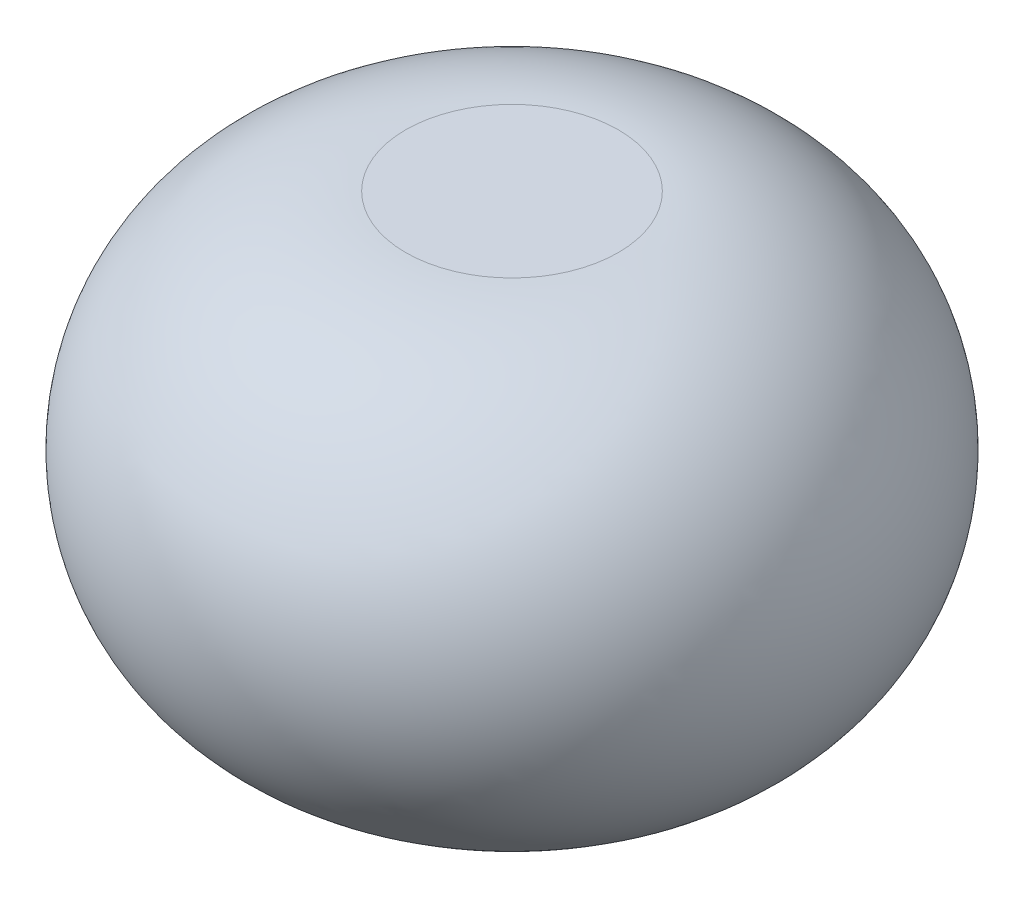
from build123d import *


with BuildPart() as part:
    # Szkic2 → Obrót-cienka ścianka1 (revolve)
    with BuildSketch(Plane.XY):
        with BuildLine():
            Line((0, 4200), (1000, 4200))
            ThreePointArc((1000, 4200), (3100, 2100), (1000, 0))
            Line((1000, 0), (0, 0))
            Line((0, 0), (0, 1))
            Line((0, 1), (1000, 1))
            ThreePointArc((1000, 1), (3099, 2100), (1000, 4199))
            Line((1000, 4199), (0, 4199))
            Line((0, 4199), (0, 4200))
        make_face()
    revolve(axis=Axis((0, 0, 0), (0, 1, 0)))


solid = part.part
